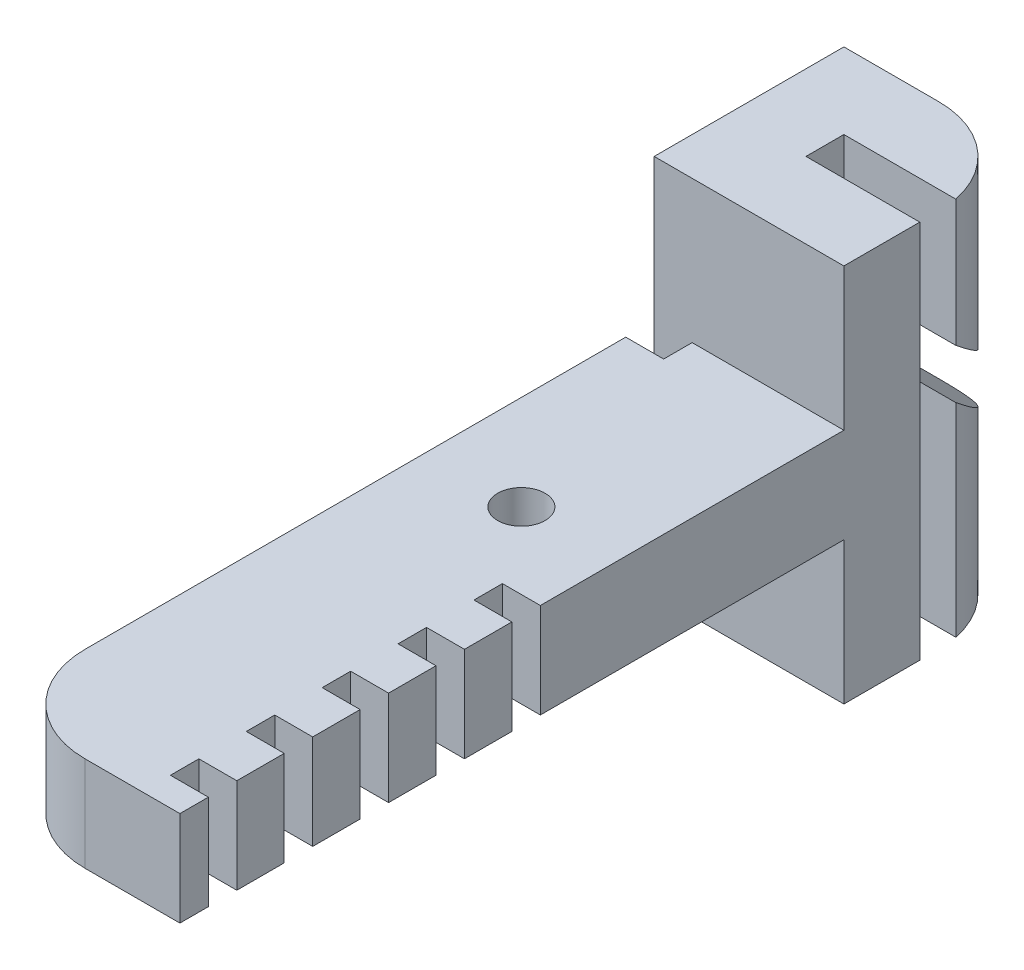
from build123d import *

# Parameters (mm, degrees)
SKETCH1_W            = 10
SKETCH1_H            = 10
BOSS_EXTRUDE1_DEPTH  = 10
SKETCH2_W            = 10
SKETCH2_H            = 5
BOSS_EXTRUDE2_DEPTH  = 35
SKETCH3_R            = 1.25
CUT_EXTRUDE1_DEPTH   = 5
FILLET1_R            = 5
SKETCH4_W            = 6
SKETCH4_H            = 2
CUT_EXTRUDE2_DEPTH   = 20
SKETCH6_W            = 1.5
SKETCH6_H            = 5
CUT_EXTRUDE3_DEPTH   = 2
CUT_EXTRUDE4_DEPTH   = 10
LPATTERN1_COUNT      = 9
LPATTERN1_PITCH      = 4
LPATTERN1_COUNT_DIR2 = 2
LPATTERN1_PITCH_DIR2 = 8


with BuildPart() as part:
    # Sketch1 → Boss-Extrude1 (new body, symmetric)
    with BuildSketch(Plane(origin=(0, 0, 0), x_dir=(1, 0, 0), z_dir=(0, 1, 0))):
        Rectangle(SKETCH1_W, SKETCH1_H)
    extrude(amount=BOSS_EXTRUDE1_DEPTH, both=True)

    # Sketch2 → Boss-Extrude2 (add)
    with BuildSketch(Plane.XY.offset(5)):
        Rectangle(SKETCH2_W, SKETCH2_H)
    extrude(amount=BOSS_EXTRUDE2_DEPTH)

    # Sketch3 → Cut-Extrude1 (cut)
    with BuildSketch(Plane(origin=(0, 2.5, 0), x_dir=(1, 0, 0), z_dir=(0, 1, 0))):
        with Locations((0, -17)):
            Circle(SKETCH3_R)
    extrude(amount=-CUT_EXTRUDE1_DEPTH, mode=Mode.SUBTRACT)

    # Fillet1
    fillet1_edges = [part.edges().sort_by_distance(p)[0] for p in [
        (-5, 0, 40),
        (5, 0, -5),
    ]]
    fillet(fillet1_edges, radius=FILLET1_R)

    # Sketch4 → Cut-Extrude2 (cut)
    with BuildSketch(Plane(origin=(0, 10, 0), x_dir=(1, 0, 0), z_dir=(0, 1, 0))):
        with Locations((2, 0)):
            Rectangle(SKETCH4_W, SKETCH4_H)
    extrude(amount=-CUT_EXTRUDE2_DEPTH, mode=Mode.SUBTRACT)

    # Sketch6 → Cut-Extrude3 (cut)
    with BuildSketch(Plane.ZY.offset(5)):
        with Locations((5.75, 0)):
            Rectangle(SKETCH6_W, SKETCH6_H)
    cut_extrude3 = extrude(amount=-CUT_EXTRUDE3_DEPTH, mode=Mode.SUBTRACT)

    # Sketch7 → Cut-Extrude4 (cut)
    with BuildSketch(Plane(origin=(-1, 0, 0), x_dir=(0, 0, -1), z_dir=(1, 0, 0))):
        Polygon((-1, 5), (11.1033346, -5.155903599), (9.817759381, -6.687992485), (-1, 2.389185421), align=None)
    extrude(amount=CUT_EXTRUDE4_DEPTH, mode=Mode.SUBTRACT)

    # LPattern1: Cut-Extrude3 9 × 2, 12 skipped
    with Locations(*[(j * LPATTERN1_PITCH_DIR2, 0, i * LPATTERN1_PITCH) for i in range(LPATTERN1_COUNT) for j in range(LPATTERN1_COUNT_DIR2) if (i, j) not in ((0, 0), (0, 1), (1, 0), (1, 1), (2, 0), (2, 1), (3, 0), (3, 1), (4, 0), (5, 0), (6, 0), (7, 0), (8, 0))]):
        add(cut_extrude3, mode=Mode.SUBTRACT)


solid = part.part
